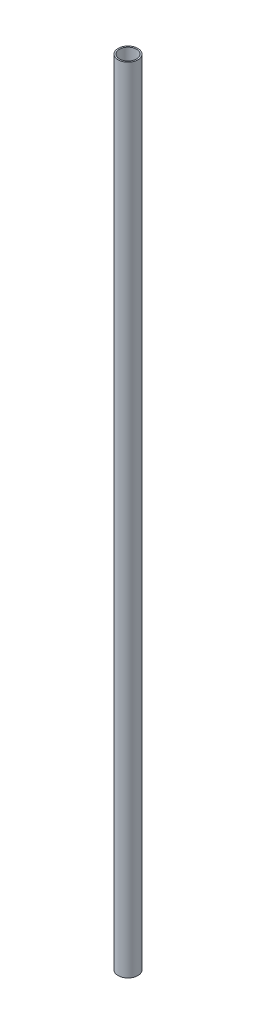
from build123d import *

# Parameters (mm, degrees)
SKETCH1_R           = 6.35
SKETCH1_R_2         = 5.461
BOSS_EXTRUDE1_DEPTH = 508


with BuildPart() as part:
    # Sketch1 → Boss-Extrude1 (new body)
    with BuildSketch(Plane(origin=(0, 0, 0), x_dir=(1, 0, 0), z_dir=(0, 1, 0))):
        Circle(SKETCH1_R)
        Circle(SKETCH1_R_2, mode=Mode.SUBTRACT)
    extrude(amount=BOSS_EXTRUDE1_DEPTH)


solid = part.part
